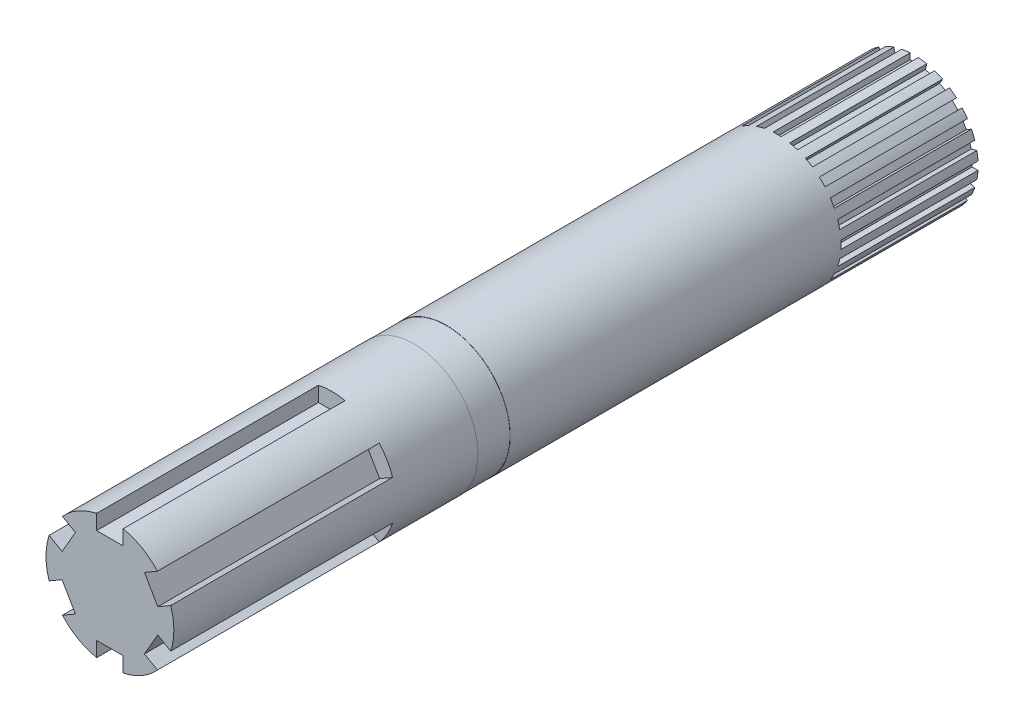
from build123d import *

# Parameters (mm, degrees)
SKETCH1_R           = 7.925000025
BOSS_EXTRUDE1_DEPTH = 58.000000078
SKETCH2_R           = 7.899999948
BOSS_EXTRUDE2_DEPTH = 4
SKETCH3_R           = 7.925000025
BOSS_EXTRUDE3_DEPTH = 37.7
SKETCH4_W           = 3.302
SKETCH4_H           = 27.5
CUT_EXTRUDE1_DEPTH  = 2.032
CIRPATTERN1_COUNT   = 6
SKETCH10_W          = 1
SKETCH10_H          = 17
CUT_EXTRUDE2_DEPTH  = 0.75
CIRPATTERN2_COUNT   = 24


with BuildPart() as part:
    # Sketch1 → Boss-Extrude1 (new body)
    with BuildSketch(Plane.XY):
        Circle(SKETCH1_R)
    extrude(amount=BOSS_EXTRUDE1_DEPTH)

    # Sketch2 → Boss-Extrude2 (add)
    with BuildSketch(Plane.XY.offset(58.000000078)):
        Circle(SKETCH2_R)
    extrude(amount=BOSS_EXTRUDE2_DEPTH)

    # Sketch3 → Boss-Extrude3 (add)
    with BuildSketch(Plane.XY.offset(62.000000078)):
        Circle(SKETCH3_R)
    extrude(amount=BOSS_EXTRUDE3_DEPTH)

    # Sketch4 → Cut-Extrude1 (cut)
    with BuildSketch(Plane(origin=(0, 7.925000025, 0), x_dir=(1, 0, 0), z_dir=(0, 1, 0))):
        with Locations((0, -85.950000078)):
            Rectangle(SKETCH4_W, SKETCH4_H)
    cut_extrude1 = extrude(amount=-CUT_EXTRUDE1_DEPTH, mode=Mode.SUBTRACT)

    # CirPattern1: Cut-Extrude1 ×6 about axis
    cirpattern1_axis = Axis((0, 0, 0), (0, 0, 1))
    for i in range(1, CIRPATTERN1_COUNT):
        add(cut_extrude1.rotate(cirpattern1_axis, i * 360 / CIRPATTERN1_COUNT), mode=Mode.SUBTRACT)

    # Sketch10 → Cut-Extrude2 (cut)
    with BuildSketch(Plane(origin=(0, 7.925000025, 0), x_dir=(1, 0, 0), z_dir=(0, 1, 0))):
        with Locations((0, -8.5)):
            Rectangle(SKETCH10_W, SKETCH10_H)
    cut_extrude2 = extrude(amount=-CUT_EXTRUDE2_DEPTH, mode=Mode.SUBTRACT)

    # CirPattern2: Cut-Extrude2 ×24 about axis
    cirpattern2_axis = Axis((0, 0, 0), (0, 0, 1))
    for i in range(1, CIRPATTERN2_COUNT):
        add(cut_extrude2.rotate(cirpattern2_axis, i * 360 / CIRPATTERN2_COUNT), mode=Mode.SUBTRACT)


solid = part.part
